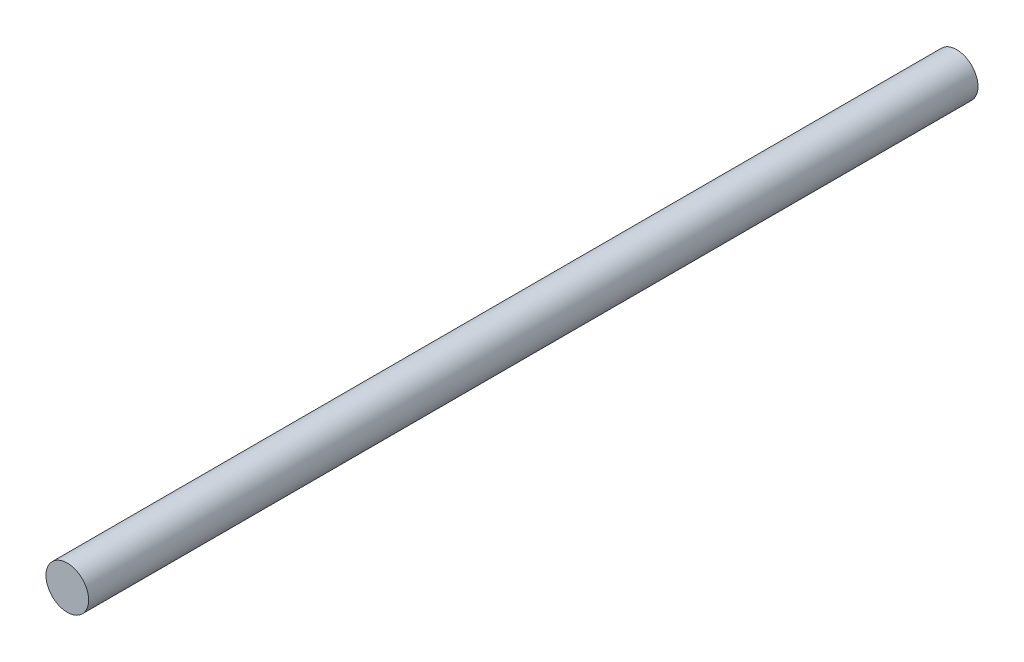
from build123d import *

# Parameters (mm, degrees)
CROQUIS1_R              = 3
SALIENTE_EXTRUIR1_DEPTH = 125


with BuildPart() as part:
    # Croquis1 → Saliente-Extruir1 (new body)
    with BuildSketch(Plane.XY):
        Circle(CROQUIS1_R)
    extrude(amount=SALIENTE_EXTRUIR1_DEPTH)


solid = part.part
